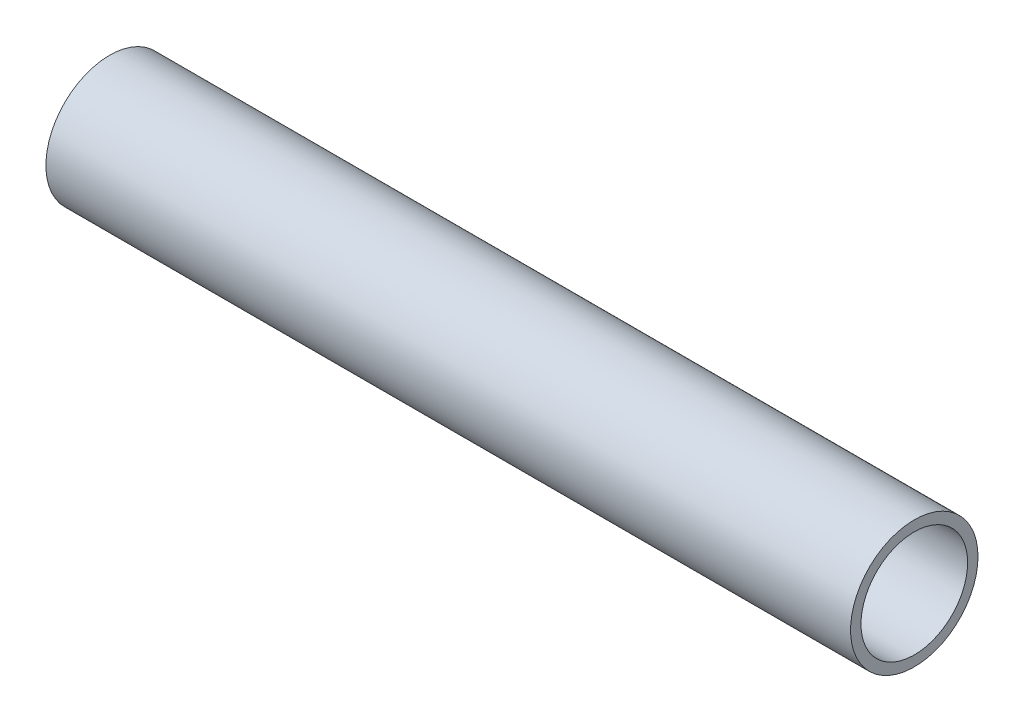
from build123d import *

# Parameters (mm, degrees)
SKETCH1_R           = 24.13
SKETCH1_R_2         = 20.193
BOSS_EXTRUDE1_DEPTH = 304.8


with BuildPart() as part:
    # Sketch1 → Boss-Extrude1 (new body)
    with BuildSketch(Plane(origin=(0, 0, 0), x_dir=(0, 0, -1), z_dir=(1, 0, 0))):
        Circle(SKETCH1_R)
        Circle(SKETCH1_R_2, mode=Mode.SUBTRACT)
    extrude(amount=BOSS_EXTRUDE1_DEPTH)


solid = part.part
